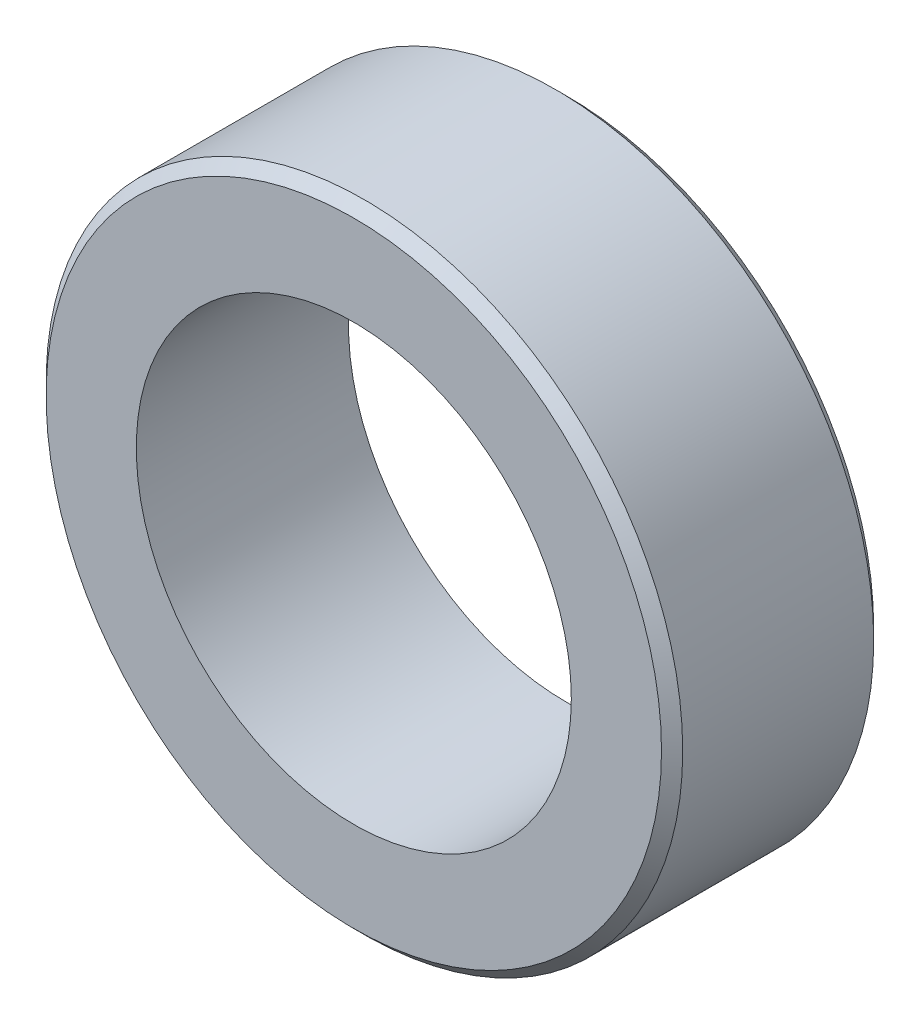
from build123d import *

# Parameters (mm, degrees)
SKETCH_1_R      = 3
SKETCH_1_R_2    = 2.05
EXTRUDE_1_DEPTH = 2
CHAMFER_1_SIZE  = 0.1


with BuildPart() as part:
    # 草图1 → 凸台-拉伸1 (new body)
    with BuildSketch(Plane.XY):
        Circle(SKETCH_1_R)
        Circle(SKETCH_1_R_2, mode=Mode.SUBTRACT)
    extrude(amount=EXTRUDE_1_DEPTH)

    # 倒角1
    chamfer_1_edges = [part.edges().sort_by_distance(p)[0] for p in [
        (-3, 0, 0),
        (-3, 0, 2),
    ]]
    chamfer(chamfer_1_edges, length=CHAMFER_1_SIZE)


solid = part.part
